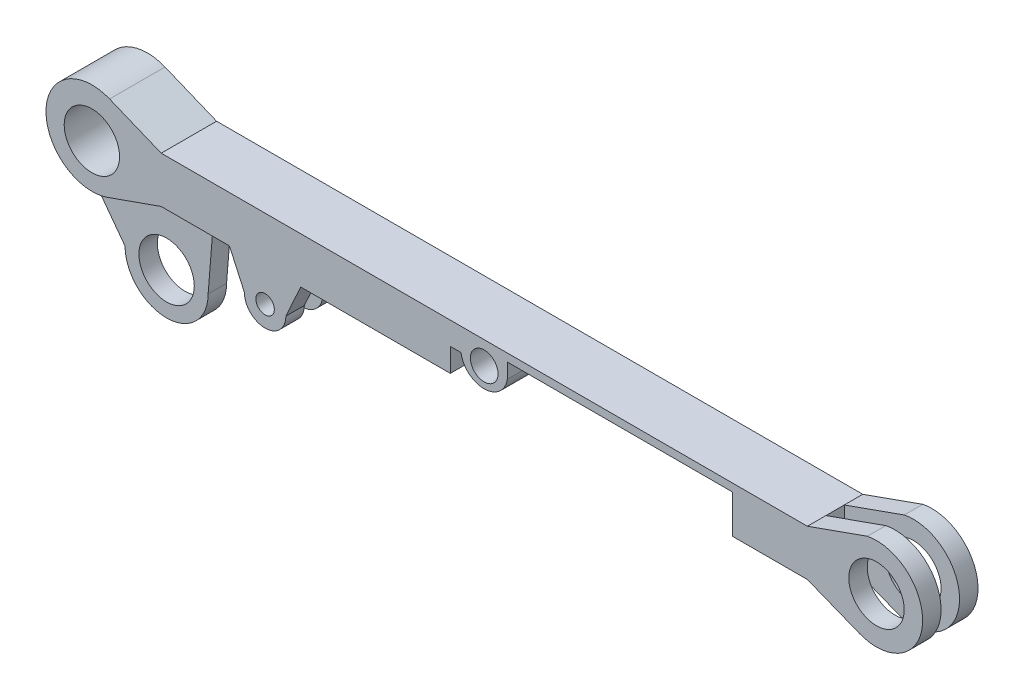
from build123d import *
from build123d.topology import SkipClean

# Parameters (mm, degrees)
BOSS_EXTRUDE1_DEPTH  = 300
SKETCH2_OUTSIDE_W    = 1151.978
SKETCH2_OUTSIDE_H    = 502.25
CUT_EXTRUDE1_DEPTH   = 1000
SKETCH31_OUTSIDE_W   = 1151.978
SKETCH31_OUTSIDE_H   = 502.25
CUT_EXTRUDE13_DEPTH  = 250
CUT_EXTRUDE14_REACH  = 483.512
SKETCH33_R           = 30
SKETCH34_W           = 75.804148239
SKETCH34_H           = 20
BOSS_EXTRUDE8_DEPTH  = 50
SKETCH36_R           = 22.5
SKETCH36_R_2         = 10
BOSS_EXTRUDE9_DEPTH  = 60
SKETCH37_R           = 15
CUT_EXTRUDE15_DEPTH  = 60
SKETCH40_W           = 20
SKETCH40_H           = 60.662429819
CUT_EXTRUDE16_DEPTH  = 190
BOSS_EXTRUDE10_START = 20
BOSS_EXTRUDE10_DEPTH = 20
CUT_EXTRUDE17_START  = -190
SKETCH42_R           = 30
CUT_EXTRUDE17_DEPTH  = 190
SKETCH43_R           = 45
SKETCH43_R_2         = 30
BOSS_EXTRUDE11_DEPTH = 20
SKETCH16_W           = 76.426632505
SKETCH16_H           = 20
BOSS_EXTRUDE5_DEPTH  = 50
CUT_EXTRUDE18_DEPTH  = 60


with BuildPart() as part:
    # Sketch1 → Boss-Extrude1 (new body)
    with BuildSketch(Plane.XY):
        with BuildLine():
            Line((350.126678984, 24.643496119), (-349.873321016, 24.643496119))
            Line((-349.873321016, 24.643496119), (-405.7801007, 47.538028277))
            ThreePointArc((-405.7801007, 47.538028277), (-474.713018176, 2.509970806), (-408.102340797, -45.887247404))
            Line((-408.102340797, -45.887247404), (-349.873321016, -25.356503881))
            Line((-349.873321016, -25.356503881), (350.126678984, -25.356503881))
            Line((350.126678984, -25.356503881), (406.56125394, -47.746215249))
            ThreePointArc((406.56125394, -47.746215249), (474.7986376, -5.753101083), (415.157857426, 47.751473547))
            Line((415.157857426, 47.751473547), (401.702587644, 42.970319678))
            Line((401.702587644, 42.970319678), (350.126678984, 24.643496119))
        make_face()
    extrude(amount=BOSS_EXTRUDE1_DEPTH)

    # Sketch2 outside → Cut-Extrude1 (cut)
    with BuildSketch(Plane(origin=(0, 24.643496119, 0), x_dir=(1, 0, 0), z_dir=(0, 1, 0))):
        with Locations((0.136, -150)):
            Rectangle(SKETCH2_OUTSIDE_W, SKETCH2_OUTSIDE_H)
        Polygon((475, -124.923454888), (350.126678984, -124.923454888), (273.700046479, -124.923454888), (-0.184563149, -124.923454888), (-274.069172777, -124.923454888), (-349.873321016, -124.923454888), (-474.728457358, -124.923454888), (-474.728457358, -144.923454888), (-349.873321016, -144.923454888), (-274.069172777, -144.923454888), (-274.069172777, -164.923454888), (-349.873321016, -164.923454888), (-474.728457358, -164.923454888), (-474.728457358, -184.923454888), (-349.873321016, -184.923454888), (-274.069172777, -184.923454888), (273.700046479, -184.923454888), (350.126678984, -184.923454888), (479.145365595, -184.923454888), (479.145365595, -164.923454888), (350.126678984, -164.923454888), (273.700046479, -164.923454888), (273.700046479, -144.923454888), (350.126678984, -144.923454888), (475, -144.923454888), align=None, mode=Mode.SUBTRACT)
    extrude(amount=-CUT_EXTRUDE1_DEPTH, mode=Mode.SUBTRACT)

    # Sketch31 outside → Cut-Extrude13 (cut, symmetric)
    with BuildSketch(Plane(origin=(0, 24.643496119, 0), x_dir=(1, 0, 0), z_dir=(0, 1, 0))):
        with Locations((0.136, -150)):
            Rectangle(SKETCH31_OUTSIDE_W, SKETCH31_OUTSIDE_H)
        Polygon((-474.728457358, -124.923454888), (475, -124.923454888), (475, -144.923454888), (273.700046479, -144.923454888), (273.700046479, -164.923454888), (475, -164.923454888), (475, -184.923454888), (-474.728457358, -184.923454888), (-474.728457358, -164.923454888), (-274.069172777, -164.923454888), (-274.069172777, -144.923454888), (-474.728457358, -144.923454888), align=None, mode=Mode.SUBTRACT)
    extrude(amount=CUT_EXTRUDE13_DEPTH, both=True, mode=Mode.SUBTRACT)

    # Cut-Extrude14: up to this face of the body (flat: up to its plane)
    cut_extrude14_end = Plane(part.part.faces().sort_by_distance((0.002005982, -0.266752761, 124.923454888))[0])
    # Sketch33 → Cut-Extrude14 (cut, up to the picked face)
    with BuildSketch(Plane.XY.offset(184.923454888), mode=Mode.PRIVATE) as cut_extrude14_sk1:
        with Locations((425, -1.27027907)):
            Circle(SKETCH33_R)
    cut_extrude14_tool1 = split(extrude(cut_extrude14_sk1.sketch, amount=-CUT_EXTRUDE14_REACH, mode=Mode.PRIVATE), bisect_by=cut_extrude14_end, keep=Keep.BOTH, mode=Mode.PRIVATE)
    cut_extrude14 = cut_extrude14_tool1.solids().sort_by(Axis((425, -1.270279, 184.923455), (0, 0, -1)))[0]
    add(cut_extrude14, mode=Mode.SUBTRACT)

    # Mirror2: Cut-Extrude14 across plane
    add(cut_extrude14.mirror(Plane(origin=(0, 0, 0), x_dir=(0, 0, 1), z_dir=(1, 0, 0))), mode=Mode.SUBTRACT)

    # Sketch34 → Boss-Extrude8 (add)
    with BuildSketch(Plane.XZ.offset(25.356503881)):
        with Locations((-311.971246897, 154.923454888)):
            Rectangle(SKETCH34_W, SKETCH34_H)
    extrude(amount=-BOSS_EXTRUDE8_DEPTH)

    # Sketch36 → Boss-Extrude9 (add)
    # profile 1 of 2: a face of its own
    with BuildSketch(Plane.XY.offset(184.923454888)):
        with BuildLine():
            Line((-198.76239189, -25.356503881), (-275.950626286, -25.356503881))
            Line((-275.950626286, -25.356503881), (-259.856509088, -60.730156187))
            ThreePointArc((-259.856509088, -60.730156187), (-237.356509088, -38.230156187), (-214.856509088, -60.730156187))
            Line((-214.856509088, -60.730156187), (-198.76239189, -25.356503881))
        make_face()
    # profile 2 of 2: a face of its own
    with BuildSketch(Plane.XY.offset(184.923454888)):
        with Locations((-237.356509088, -60.730156187)):
            Circle(SKETCH36_R)
        with Locations((-237.356509088, -60.730156187)):
            Circle(SKETCH36_R_2, mode=Mode.SUBTRACT)
    extrude(amount=-BOSS_EXTRUDE9_DEPTH)

    # Sketch37 → Cut-Extrude15 (cut)
    with BuildSketch(Plane.XY.offset(184.923454888)):
        Circle(SKETCH37_R)
    extrude(amount=-CUT_EXTRUDE15_DEPTH, mode=Mode.SUBTRACT)

    # Sketch40 → Cut-Extrude16 (cut)
    with BuildSketch(Plane.ZY.offset(349.873321016)):
        with Locations((154.923454888, -55.68771879)):
            Rectangle(SKETCH40_W, SKETCH40_H)
    extrude(amount=-CUT_EXTRUDE16_DEPTH, mode=Mode.SUBTRACT)

    # Sketch41 → Boss-Extrude10 (add)
    with SkipClean():  # the faces are left unmerged after this step: merging them gives an invalid solid
        with BuildSketch(Plane(origin=(0, 0, 164.923454888), x_dir=(-1, 0, 0), z_dir=(0, 0, -1)).offset(BOSS_EXTRUDE10_START)):
            with BuildLine():
                Line((349.873321016, 24.643496119), (349.873321016, -25.356503881))
                Line((349.873321016, -25.356503881), (408.102340797, -45.887247404))
                ThreePointArc((408.102340797, -45.887247404), (474.713018176, 2.509970806), (405.7801007, 47.538028277))
                Line((405.7801007, 47.538028277), (349.873321016, 24.643496119))
            make_face()
        extrude(amount=-BOSS_EXTRUDE10_DEPTH)

    # Sketch42 → Cut-Extrude17 (cut)
    with SkipClean():  # the faces are left unmerged after this step: merging them gives an invalid solid
        with BuildSketch(Plane(origin=(0, 0, 144.923454888), x_dir=(-1, 0, 0), z_dir=(0, 0, -1)).offset(CUT_EXTRUDE17_START)):
            with Locations((425, -1.27027907)):
                Circle(SKETCH42_R)
        extrude(amount=CUT_EXTRUDE17_DEPTH, mode=Mode.SUBTRACT)

    # Sketch43 → Boss-Extrude11 (add)
    # profile 1 of 2: a face of its own
    with SkipClean():  # the faces are left unmerged after this step: merging them gives an invalid solid
        with BuildSketch(Plane.XY.offset(144.923454888)):
            with BuildLine():
                ThreePointArc((-408.102340797, -45.887247404), (-434.883748111, -47.690318028), (-458.738421585, -35.383840268))
                Line((-458.738421585, -35.383840268), (-409.065603299, -102.059498008))
                ThreePointArc((-409.065603299, -102.059498008), (-364.065603299, -57.059498008), (-319.065603299, -102.059498008))
                Line((-319.065603299, -102.059498008), (-312.911973651, -25.356503881))
                Line((-312.911973651, -25.356503881), (-349.873321016, -25.356503881))
                Line((-349.873321016, -25.356503881), (-408.102340797, -45.887247404))
            make_face()
        # profile 2 of 2: a face of its own
        with BuildSketch(Plane.XY.offset(144.923454888)):
            with Locations((-364.065603299, -102.059498008)):
                Circle(SKETCH43_R)
            with Locations((-364.065603299, -102.059498008)):
                Circle(SKETCH43_R_2, mode=Mode.SUBTRACT)
        extrude(amount=BOSS_EXTRUDE11_DEPTH)

    # Sketch16 → Boss-Extrude5 (add)
    with SkipClean():  # the faces are left unmerged after this step: merging them gives an invalid solid
        with BuildSketch(Plane(origin=(0, 24.643496119, 0), x_dir=(1, 0, 0), z_dir=(0, 1, 0))):
            with Locations((311.913362732, -154.923454888)):
                Rectangle(SKETCH16_W, SKETCH16_H)
        extrude(amount=-BOSS_EXTRUDE5_DEPTH)

    # Sketch44 → Cut-Extrude18 (cut)
    with SkipClean():  # the faces are left unmerged after this step: merging them gives an invalid solid
        with BuildSketch(Plane.XY.offset(184.923454888)):
            with BuildLine():
                Line((-25.160479447, 0), (-36.658076152, 0))
                Line((-36.658076152, 0), (-36.658076152, -25.356503881))
                Line((-36.658076152, -25.356503881), (269.253650874, -25.356503881))
                Line((269.253650874, -25.356503881), (269.253650874, 16.212961512))
                Line((269.253650874, 16.212961512), (25.088276522, 16.212961512))
                Line((25.088276522, 16.212961512), (25.088276522, 0))
                ThreePointArc((25.088276522, 0), (-0.036101462, -21.533407162), (-25.160479447, 0))
            make_face()
        extrude(amount=-CUT_EXTRUDE18_DEPTH, mode=Mode.SUBTRACT)


solid = part.part
